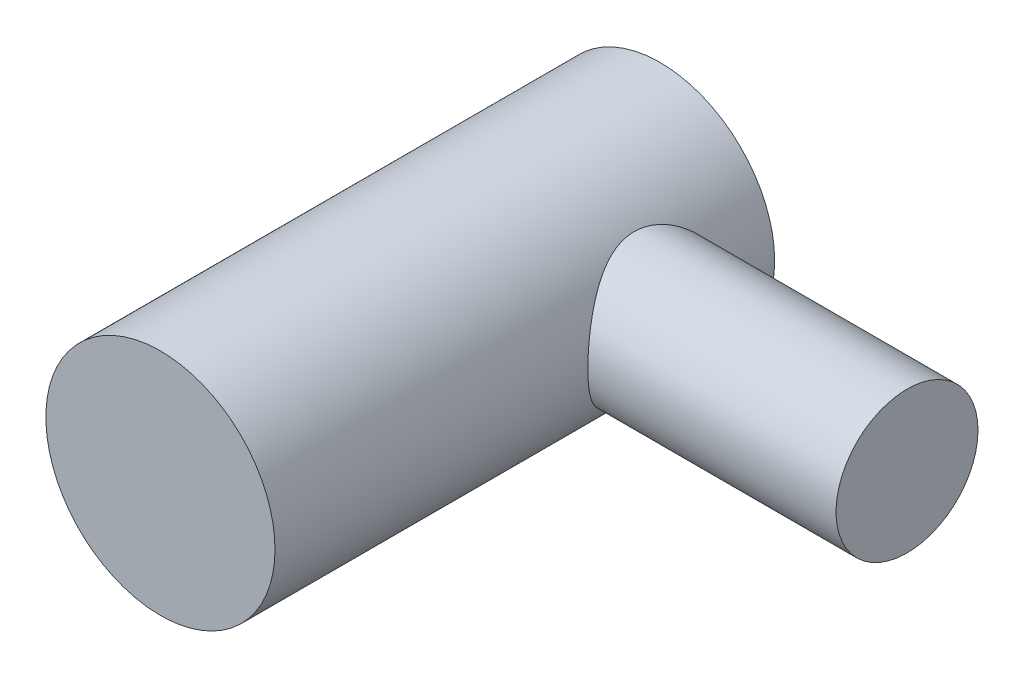
from build123d import *

# Parameters (mm, degrees)
SKETCH1_R           = 18
BOSS_EXTRUDE1_DEPTH = 78.5
SKETCH4_R           = 11.15
BOSS_EXTRUDE3_DEPTH = 57


with BuildPart() as part:
    # Sketch1 → Boss-Extrude1 (new body)
    with BuildSketch(Plane.XY):
        Circle(SKETCH1_R)
    extrude(amount=BOSS_EXTRUDE1_DEPTH)

    # Sketch4 → Boss-Extrude3 (add)
    with BuildSketch(Plane(origin=(0, 0, 0), x_dir=(0, 0, -1), z_dir=(1, 0, 0))):
        with Locations((-18.2, 0)):
            Circle(SKETCH4_R)
    extrude(amount=BOSS_EXTRUDE3_DEPTH)


solid = part.part
